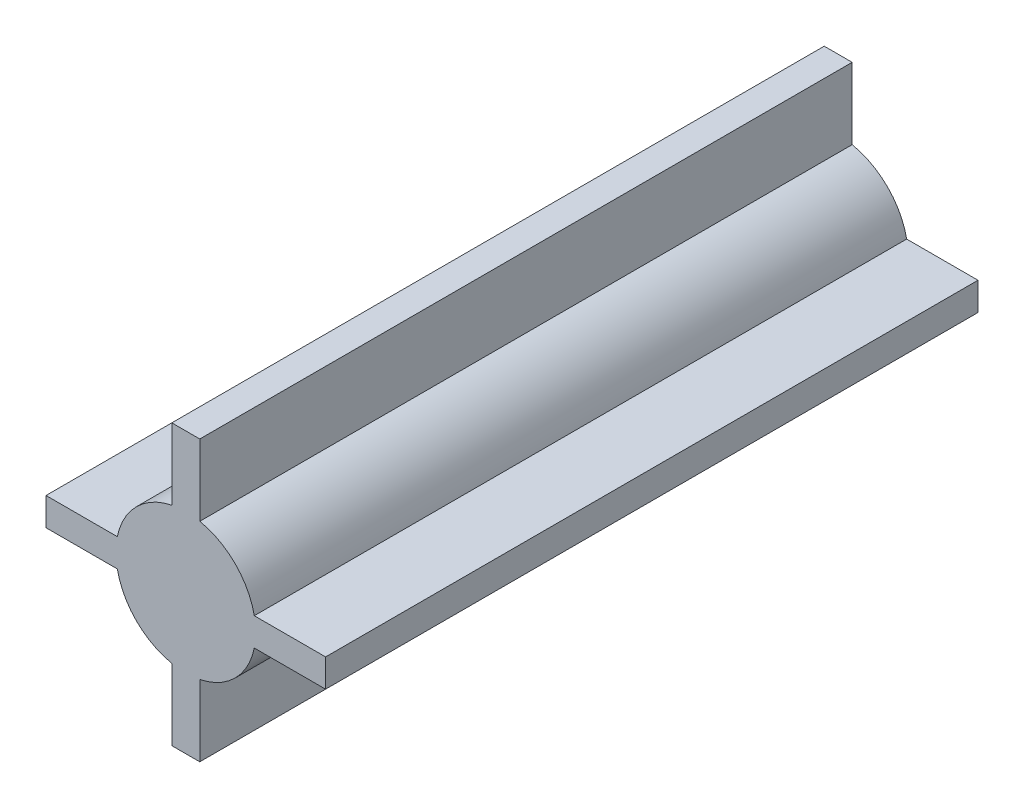
from build123d import *

# Parameters (mm, degrees)
SKETCH1_R           = 7.5
SKETCH1_W           = 30
SKETCH1_H           = 3
SKETCH1_W_2         = 3
SKETCH1_H_2         = 30
BOSS_EXTRUDE2_DEPTH = 70


with BuildPart() as part:
    # Sketch1 → Boss-Extrude2 (new body)
    with BuildSketch(Plane.XY):
        Circle(SKETCH1_R)
        Rectangle(SKETCH1_W, SKETCH1_H)
        Rectangle(SKETCH1_W_2, SKETCH1_H_2)
    extrude(amount=BOSS_EXTRUDE2_DEPTH)


solid = part.part
